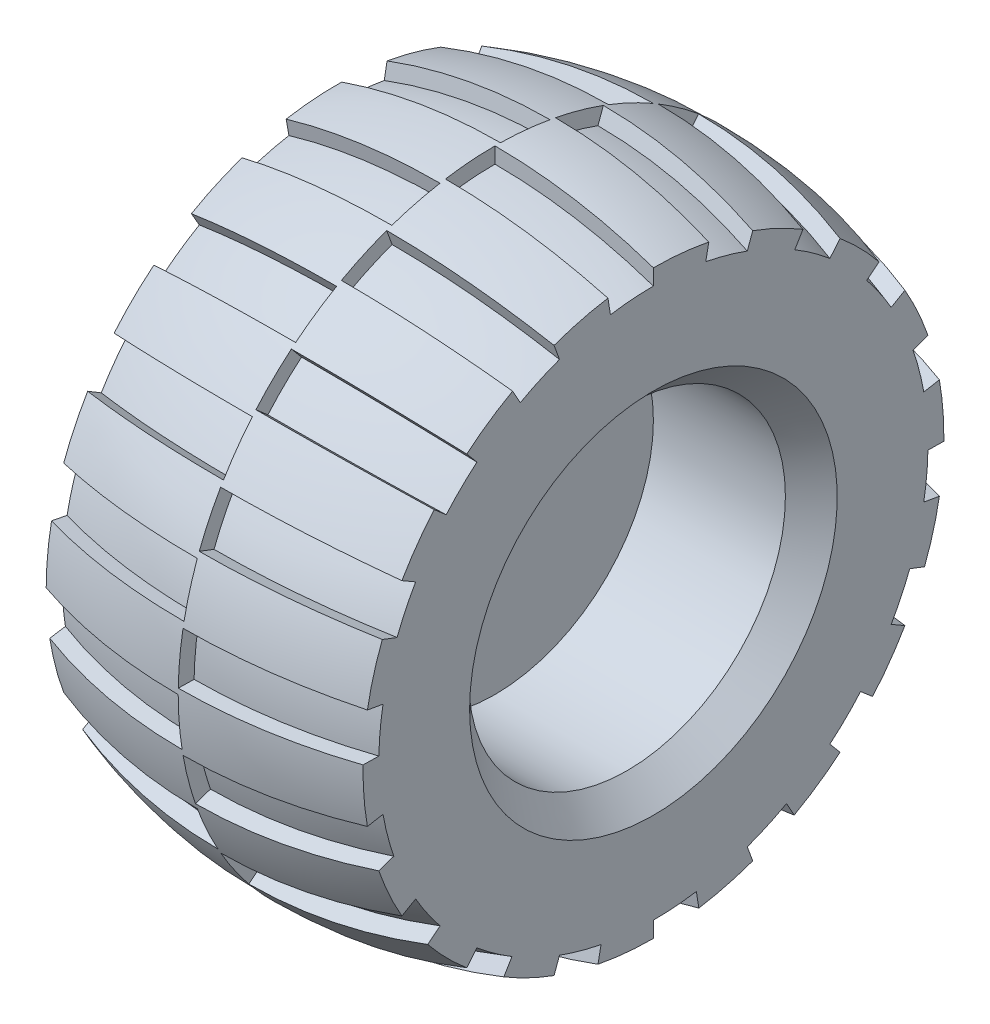
from build123d import *

# Parameters (mm, degrees)
CUT_REVOLVE2_ANGLE  = 9
CIRPATTERN2_COUNT   = 18
CUT_REVOLVE3_ANGLE  = 9
CIRPATTERN3_COUNT   = 18
SKETCH9_R           = 30
BOSS_EXTRUDE2_DEPTH = 25
SKETCH10_R          = 5
BOSS_EXTRUDE3_DEPTH = 14


with BuildPart() as part:
    # Sketch1 → Revolve1 (revolve)
    with BuildSketch(Plane.XY, mode=Mode.PRIVATE) as revolve1_sk:
        with BuildLine():
            Line((-25, 30), (25, 30))
            Line((25, 30), (30, 34.813257))
            Line((30, 34.813257), (30, 55))
            ThreePointArc((30, 55), (0, 60), (-30, 55))
            Line((-30, 55), (-30, 34.813257))
            Line((-30, 34.813257), (-25, 30))
        make_face()
    revolve(revolve1_sk.sketch.rotate(Axis((-40.614871, 0, 0), (1, 0, 0)), 90), axis=Axis((-40.614871, 0, 0), (1, 0, 0)))

    # Sketch2 → Cut-Revolve2 (revolve, cut)
    with BuildSketch(Plane.XY):
        with BuildLine():
            Line((0, 60), (0, 57))
            ThreePointArc((0, 57), (15.206906, 55.741438), (30, 52))
            Line((30, 52), (30, 55))
            ThreePointArc((30, 55), (15.206906, 58.741438), (0, 60))
        make_face()
    cut_revolve2 = revolve(axis=Axis((-40.614871, 0, 0), (1, 0, 0)), revolution_arc=CUT_REVOLVE2_ANGLE, mode=Mode.SUBTRACT)

    # CirPattern2: Cut-Revolve2 ×18 about axis
    cirpattern2_axis = Axis((0, 0, 0), (1, 0, 0))
    for i in range(1, CIRPATTERN2_COUNT):
        add(cut_revolve2.rotate(cirpattern2_axis, i * 360 / CIRPATTERN2_COUNT), mode=Mode.SUBTRACT)

    # Sketch5 → Cut-Revolve3 (revolve, cut)
    with BuildSketch(Plane(origin=(0, 0, 0), x_dir=(1, 0, 0), z_dir=(0, 0.017452, 0.999848))):
        with BuildLine():
            Line((-30, 55), (-30, 52))
            ThreePointArc((-30, 52), (-15.206906, 55.741438), (0, 57))
            Line((0, 57), (0, 60))
            ThreePointArc((0, 60), (-15.206906, 58.741438), (-30, 55))
        make_face()
    cut_revolve3 = revolve(axis=Axis((-40.614871, 0, 0), (-1, 0, 0)), revolution_arc=CUT_REVOLVE3_ANGLE, mode=Mode.SUBTRACT)

    # CirPattern3: Cut-Revolve3 ×18 about axis
    cirpattern3_axis = Axis((0, 0, 0), (1, 0, 0))
    for i in range(1, CIRPATTERN3_COUNT):
        add(cut_revolve3.rotate(cirpattern3_axis, i * 360 / CIRPATTERN3_COUNT), mode=Mode.SUBTRACT)

    # Sketch9 → Boss-Extrude2 (add)
    with BuildSketch(Plane(origin=(0, 0, 0), x_dir=(0, 0, -1), z_dir=(1, 0, 0))):
        with Locations(Location((0, 0, 0), (0, 0, 180))):
            Circle(SKETCH9_R)
    extrude(amount=-BOSS_EXTRUDE2_DEPTH)

    # Sketch10 → Boss-Extrude3 (add)
    with BuildSketch(Plane.ZY.offset(25)):
        with Locations(Location((0, 0, 0), (0, 0, 180))):
            Circle(SKETCH10_R)
    extrude(amount=BOSS_EXTRUDE3_DEPTH)


solid = part.part
